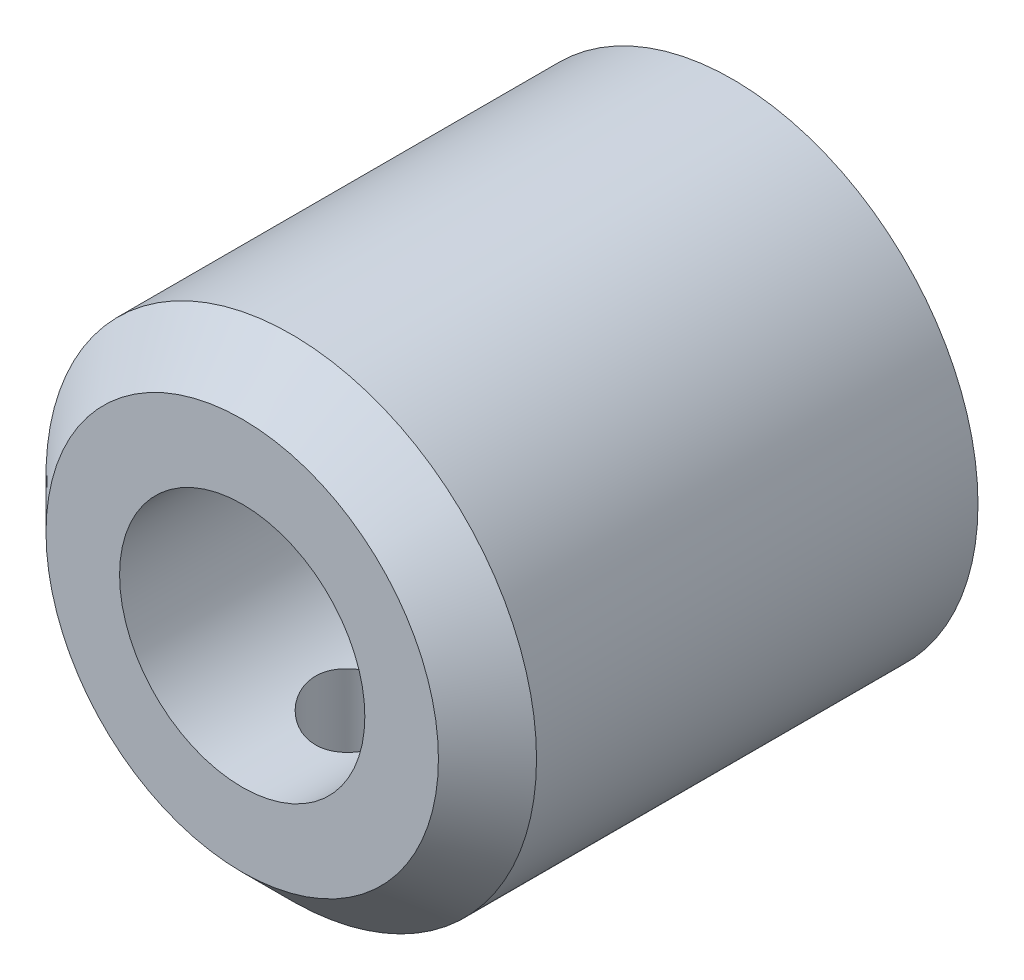
from build123d import *

# Parameters (mm, degrees)
SKETCH1_R           = 12.7
BOSS_EXTRUDE1_DEPTH = 25.4
SKETCH2_R           = 2.5527
CUT_EXTRUDE1_DEPTH  = 26.4
SKETCH3_R           = 6.35
CUT_EXTRUDE2_DEPTH  = 19.05
CHAMFER1_SIZE       = 2.54
SKETCH4_R           = 2.5527
CUT_EXTRUDE3_DEPTH  = 19.05


with BuildPart() as part:
    # Sketch1 → Boss-Extrude1 (new body)
    with BuildSketch(Plane.XY):
        Circle(SKETCH1_R)
    extrude(amount=BOSS_EXTRUDE1_DEPTH)

    # Sketch2 → Cut-Extrude1 (cut, through all)
    with BuildSketch(Plane.XY.offset(25.4)):
        Circle(SKETCH2_R)
    extrude(amount=-CUT_EXTRUDE1_DEPTH, mode=Mode.SUBTRACT)

    # Sketch3 → Cut-Extrude2 (cut)
    with BuildSketch(Plane.XY.offset(25.4)):
        Circle(SKETCH3_R)
    extrude(amount=-CUT_EXTRUDE2_DEPTH, mode=Mode.SUBTRACT)

    # Chamfer1
    chamfer1_edges = [part.edges().sort_by_distance(p)[0] for p in [
        (-12.7, 0, 25.4),
    ]]
    chamfer(chamfer1_edges, length=CHAMFER1_SIZE)

    # Sketch4 → Cut-Extrude3 (cut)
    with BuildSketch(Plane(origin=(0, 0, 0), x_dir=(1, 0, 0), z_dir=(0, 1, 0))):
        with Locations((0, -19.05)):
            Circle(SKETCH4_R)
    extrude(amount=-CUT_EXTRUDE3_DEPTH, mode=Mode.SUBTRACT)


solid = part.part
